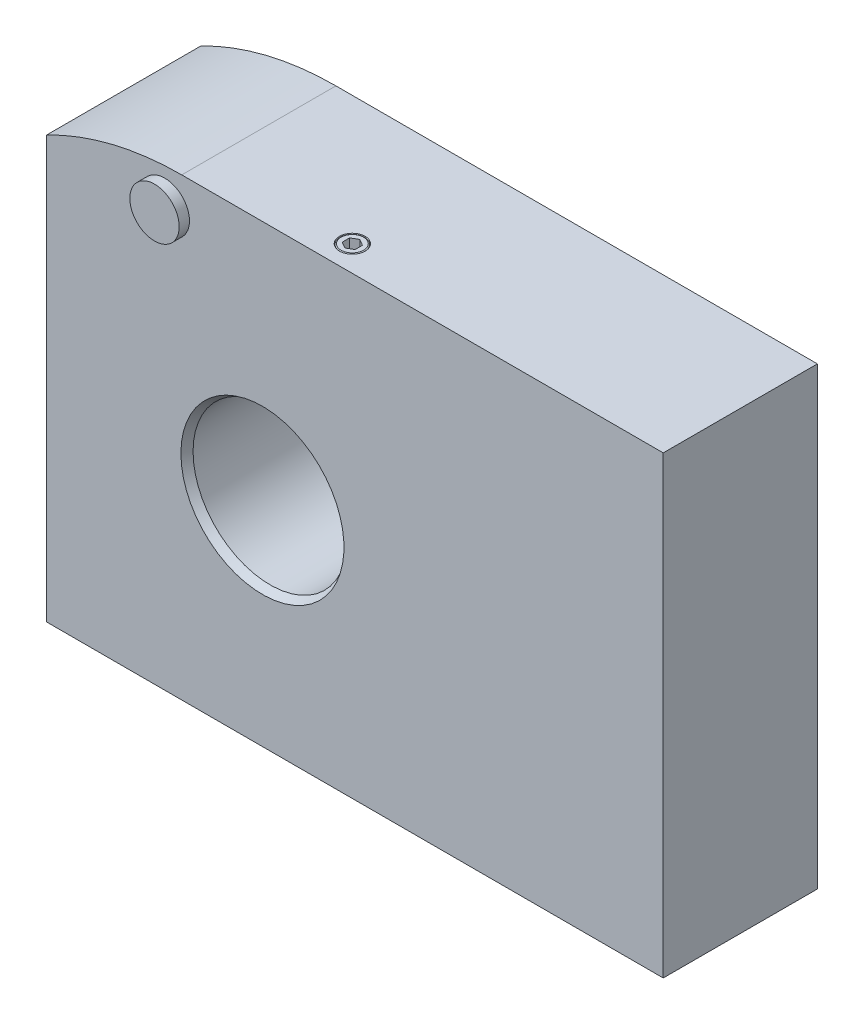
from build123d import *

# Parameters (mm, degrees)
BOSS_EXTRUDE1_DEPTH = 30
CUT_EXTRUDE1_DEPTH  = 3.8
CUT_EXTRUDE2_DEPTH  = 3.8
CUT_EXTRUDE3_DEPTH  = 3.8
CUT_EXTRUDE4_DEPTH  = 3.8
SKETCH11_R          = 4.5
CUT_EXTRUDE5_DEPTH  = 2.1
SKETCH12_R          = 4.5
CUT_EXTRUDE6_DEPTH  = 2.1
SKETCH15_R          = 4.8
BOSS_EXTRUDE2_DEPTH = 2
CUT_EXTRUDE7_DEPTH  = 3


with BuildPart() as part:
    # Sketch1 → Boss-Extrude1 (new body)
    with BuildSketch(Plane.XY):
        with BuildLine():
            Line((0, 0), (120, 0))
            Line((120, 0), (120, 88.5))
            Line((120, 88.5), (26.3, 88.5))
            ThreePointArc((26.3, 88.5), (12.762673874, 86.869132207), (0, 82.069852679))
            Line((0, 82.069852679), (0, 0))
        make_face()
    extrude(amount=-BOSS_EXTRUDE1_DEPTH)

    # Sketch2 → Cut-Revolve1 (revolve, cut)
    with BuildSketch(Plane(origin=(42, 0, 0), x_dir=(0, 0, -1), z_dir=(1, 0, 0))):
        Polygon((0, 41.5), (0, 57.366025404), (1.5, 56.5), (23, 56.5), (23, 41.5), align=None)
    revolve(axis=Axis((42, 41.5, -23), (0, 0, 1)), mode=Mode.SUBTRACT)

    # Sketch3 → Cut-Revolve2 (revolve, cut)
    with BuildSketch(Plane(origin=(100.5, 0, 0), x_dir=(0, 0, -1), z_dir=(1, 0, 0))):
        Polygon((26.2, 8), (29.2, 11), (29.2, 12.4), (28.6, 13), (23.2, 13), (23.2, 13.5), (30, 13.5), (30, 8), align=None)
    revolve(axis=Axis((100.5, 8, -30), (0, 0, 1)), mode=Mode.SUBTRACT)

    # Sketch4 → Cut-Revolve3 (revolve, cut)
    with BuildSketch(Plane(origin=(16.5, 0, 0), x_dir=(0, 0, -1), z_dir=(1, 0, 0))):
        Polygon((26.2, 6.5), (29.2, 9.5), (29.2, 10.9), (28.6, 11.5), (23.2, 11.5), (23.2, 12), (30, 12), (30, 6.5), align=None)
    revolve(axis=Axis((16.5, 6.5, -30), (0, 0, 1)), mode=Mode.SUBTRACT)

    # Sketch5 → Cut-Revolve4 (revolve, cut)
    with BuildSketch(Plane(origin=(108.5, 0, 0), x_dir=(0, 0, -1), z_dir=(1, 0, 0))):
        Polygon((26.2, 58), (29.2, 61), (29.2, 62.4), (28.6, 63), (23.2, 63), (23.2, 63.5), (30, 63.5), (30, 58), align=None)
    revolve(axis=Axis((108.5, 58, -30), (0, 0, 1)), mode=Mode.SUBTRACT)

    # Sketch6 → Cut-Revolve5 (revolve, cut)
    with BuildSketch(Plane(origin=(13, 0, 0), x_dir=(0, 0, -1), z_dir=(1, 0, 0))):
        Polygon((26.2, 49), (29.2, 52), (29.2, 53.4), (28.6, 54), (23.2, 54), (23.2, 54.5), (30, 54.5), (30, 49), align=None)
    revolve(axis=Axis((13, 49, -30), (0, 0, 1)), mode=Mode.SUBTRACT)

    # Sketch7 → Cut-Extrude1 (cut)
    with BuildSketch(Plane.XY.offset(-30)):
        Polygon((98, 9.443375673), (98, 6.556624327), (100.5, 5.113248654), (103, 6.556624327), (103, 9.443375673), (100.5, 10.886751346), align=None)
    extrude(amount=CUT_EXTRUDE1_DEPTH, mode=Mode.SUBTRACT)

    # Sketch8 → Cut-Extrude2 (cut)
    with BuildSketch(Plane.XY.offset(-30)):
        Polygon((14, 7.943375673), (14, 5.056624327), (16.5, 3.613248654), (19, 5.056624327), (19, 7.943375673), (16.5, 9.386751346), align=None)
    extrude(amount=CUT_EXTRUDE2_DEPTH, mode=Mode.SUBTRACT)

    # Sketch9 → Cut-Extrude3 (cut)
    with BuildSketch(Plane.XY.offset(-30)):
        Polygon((106, 59.443375673), (106, 56.556624327), (108.5, 55.113248654), (111, 56.556624327), (111, 59.443375673), (108.5, 60.886751346), align=None)
    extrude(amount=CUT_EXTRUDE3_DEPTH, mode=Mode.SUBTRACT)

    # Sketch10 → Cut-Extrude4 (cut)
    with BuildSketch(Plane.XY.offset(-30)):
        Polygon((10.5, 50.443375673), (10.5, 47.556624327), (13, 46.113248654), (15.5, 47.556624327), (15.5, 50.443375673), (13, 51.886751346), align=None)
    extrude(amount=CUT_EXTRUDE4_DEPTH, mode=Mode.SUBTRACT)

    # Sketch11 → Cut-Extrude5 (cut)
    with BuildSketch(Plane.XY.offset(-30)):
        with Locations((80, 21)):
            Circle(SKETCH11_R)
    extrude(amount=CUT_EXTRUDE5_DEPTH, mode=Mode.SUBTRACT)

    # Sketch12 → Cut-Extrude6 (cut)
    with BuildSketch(Plane.XY.offset(-30)):
        with Locations((40, 21)):
            Circle(SKETCH12_R)
    extrude(amount=CUT_EXTRUDE6_DEPTH, mode=Mode.SUBTRACT)

    # Sketch13 → Cut-Revolve6 (revolve, cut)
    with BuildSketch(Plane(origin=(0, 21, 0), x_dir=(1, 0, 0), z_dir=(0, 1, 0))):
        Polygon((100, 30), (104, 30), (103.3235, 29.3235), (103.3235, 8), (100, 6.08117638), align=None)
    revolve(axis=Axis((100, 21, -6.08117638), (0, 0, -1)), mode=Mode.SUBTRACT)

    # Sketch14 → Cut-Revolve7 (revolve, cut)
    with BuildSketch(Plane(origin=(0, 21, 0), x_dir=(1, 0, 0), z_dir=(0, 1, 0))):
        Polygon((20, 30), (24, 30), (23.3235, 29.3235), (23.3235, 8), (20, 6.08117638), align=None)
    revolve(axis=Axis((20, 21, -6.08117638), (0, 0, -1)), mode=Mode.SUBTRACT)

    # Sketch15 → Boss-Extrude2 (add)
    with BuildSketch(Plane.XY):
        with Locations((23, 81.5)):
            Circle(SKETCH15_R)
    extrude(amount=BOSS_EXTRUDE2_DEPTH)

    # Sketch16 → Cut-Revolve8 (revolve, cut)
    with BuildSketch(Plane(origin=(54.5, 0, 0), x_dir=(0, 0, -1), z_dir=(1, 0, 0))):
        Polygon((5, 88.5), (2.806572993, 88.5), (2.612213504, 88.387786496), (2.5, 88.5), (2.5, 89.5), (5, 89.5), align=None)
    revolve(axis=Axis((54.5, 89.5, -5), (0, -1, 0)), mode=Mode.SUBTRACT)

    # Sketch17 → Cut-Extrude7 (cut)
    with BuildSketch(Plane(origin=(0, 88.5, 0), x_dir=(1, 0, 0), z_dir=(0, 1, 0))):
        Polygon((53.25, 5.721687836), (53.25, 4.278312164), (54.5, 3.556624327), (55.75, 4.278312164), (55.75, 5.721687836), (54.5, 6.443375673), align=None)
    extrude(amount=-CUT_EXTRUDE7_DEPTH, mode=Mode.SUBTRACT)


solid = part.part
